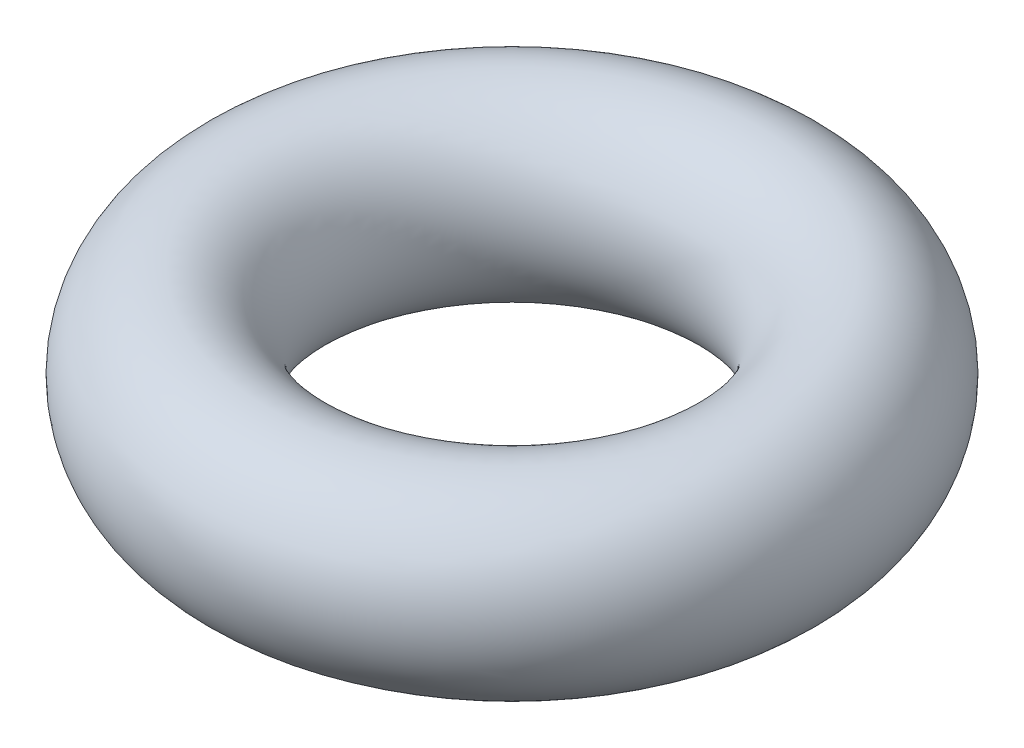
from build123d import *

# Parameters (mm, degrees)
BODY_SKETCH_RX = 0.875
BODY_SKETCH_RY = 0.8


with BuildPart() as part:
    # body_sketch → body (revolve)
    with BuildSketch(Plane.XY):
        with Locations(Location((-2.3, 0), (0, 0, 90))):
            Ellipse(BODY_SKETCH_RX, BODY_SKETCH_RY)
    revolve(axis=Axis((0, 0, 0), (0, 1, 0)))


solid = part.part
